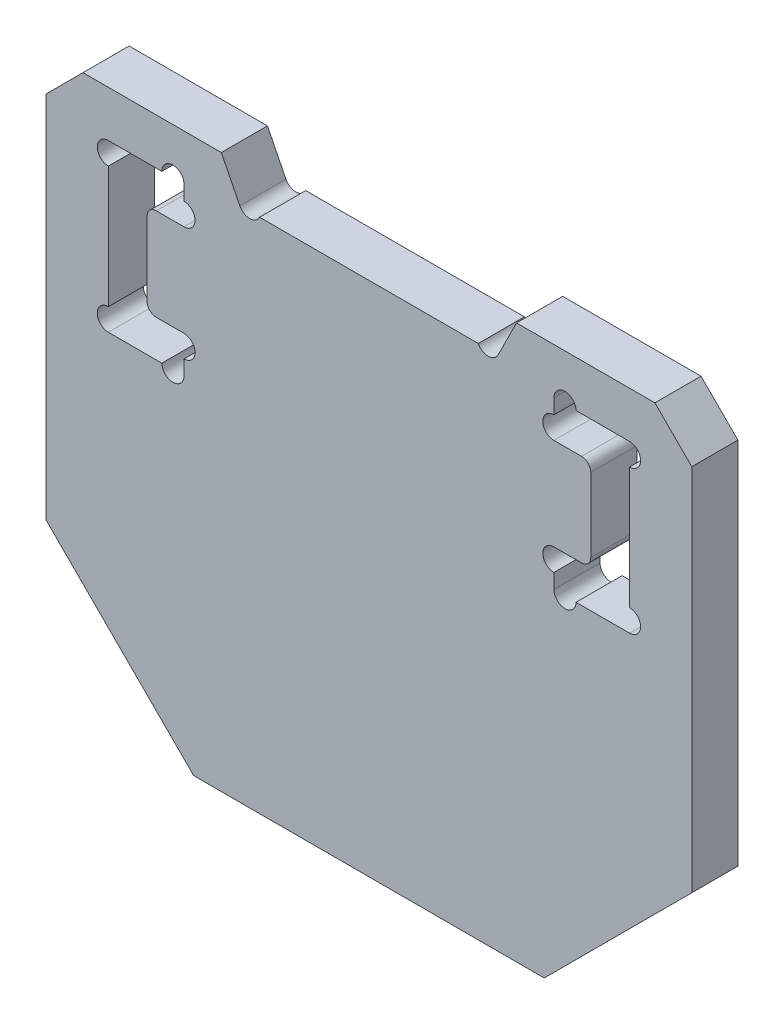
from build123d import *

# Parameters (mm, degrees)
SKETCH_1_W          = 35
SKETCH_1_H          = 30
EXTRUDE_1_DEPTH     = 1.25
CHAMFER_1_SIZE      = 8
CHAMFER_2_SIZE      = 2
CUT_EXTRUDE_1_DEPTH = 3.5
CUT_EXTRUDE_2_DEPTH = 3.5
SKETCH_5_R          = 0.6
CUT_EXTRUDE_3_DEPTH = 3.5
FILLET_1_R          = 0.5


with BuildPart() as part:
    # 草图1 → 凸台-拉伸1 (new body, symmetric)
    with BuildSketch(Plane.XY):
        with Locations((0, -15)):
            Rectangle(SKETCH_1_W, SKETCH_1_H)
    extrude(amount=EXTRUDE_1_DEPTH, both=True)

    # 倒角1
    chamfer_1_edges = [part.edges().sort_by_distance(p)[0] for p in [
        (17.5, -30, 0),
        (-17.5, -30, 0),
    ]]
    chamfer(chamfer_1_edges, length=CHAMFER_1_SIZE)

    # 倒角2
    chamfer_2_edges = [part.edges().sort_by_distance(p)[0] for p in [
        (-17.5, 0, 0),
        (17.5, 0, 0),
    ]]
    chamfer(chamfer_2_edges, length=CHAMFER_2_SIZE)

    # 草图2 → 切除-拉伸1 (cut, through all)
    with BuildSketch(Plane.XY.offset(1.25)):
        Polygon((-8, 0), (-7, -2), (7, -2), (8, 0), align=None)
    extrude(amount=-CUT_EXTRUDE_1_DEPTH, mode=Mode.SUBTRACT)

    # 草图4 → 切除-拉伸2 (cut, through all)
    with BuildSketch(Plane.XY.offset(1.25)):
        Polygon((-14.125, -2.5), (-10.025, -2.5), (-10.025, -4.5), (-12.025, -4.5), (-12.025, -9.5), (-10.025, -9.5), (-10.025, -11.5), (-14.125, -11.5), align=None)
        Polygon((10.025, -11.5), (14.125, -11.5), (14.125, -2.5), (10.025, -2.5), (10.025, -4.5), (12.025, -4.5), (12.025, -9.5), (10.025, -9.5), align=None)
    extrude(amount=-CUT_EXTRUDE_2_DEPTH, mode=Mode.SUBTRACT)

    # 草图5 → 切除-拉伸3 (cut, through all)
    with BuildSketch(Plane.XY.offset(1.25)):
        with Locations((-14.125, -3.1)):
            Circle(SKETCH_5_R)
        with Locations((-14.125, -10.9)):
            Circle(SKETCH_5_R)
        with Locations((-10.625, -11.5)):
            Circle(SKETCH_5_R)
        with Locations((-10.025, -10.1)):
            Circle(SKETCH_5_R)
        with Locations((-10.025, -3.9)):
            Circle(SKETCH_5_R)
        with Locations((-10.625, -2.5)):
            Circle(SKETCH_5_R)
        with Locations((10.625, -2.5)):
            Circle(SKETCH_5_R)
        with Locations((10.025, -3.9)):
            Circle(SKETCH_5_R)
        with Locations((10.025, -10.1)):
            Circle(SKETCH_5_R)
        with Locations((10.625, -11.5)):
            Circle(SKETCH_5_R)
        with Locations((14.125, -10.9)):
            Circle(SKETCH_5_R)
        with Locations((14.125, -3.1)):
            Circle(SKETCH_5_R)
        with Locations((-6.463343685, -1.731671843)):
            Circle(SKETCH_5_R)
        with Locations((6.463343685, -1.731671843)):
            Circle(SKETCH_5_R)
    extrude(amount=-CUT_EXTRUDE_3_DEPTH, mode=Mode.SUBTRACT)

    # 圆角1
    fillet_1_edges = [part.edges().sort_by_distance(p)[0] for p in [
        (-12.025, -4.5, 0),
        (-12.025, -9.5, 0),
        (12.025, -9.5, 0),
        (12.025, -4.5, 0),
    ]]
    fillet(fillet_1_edges, radius=FILLET_1_R)


solid = part.part
